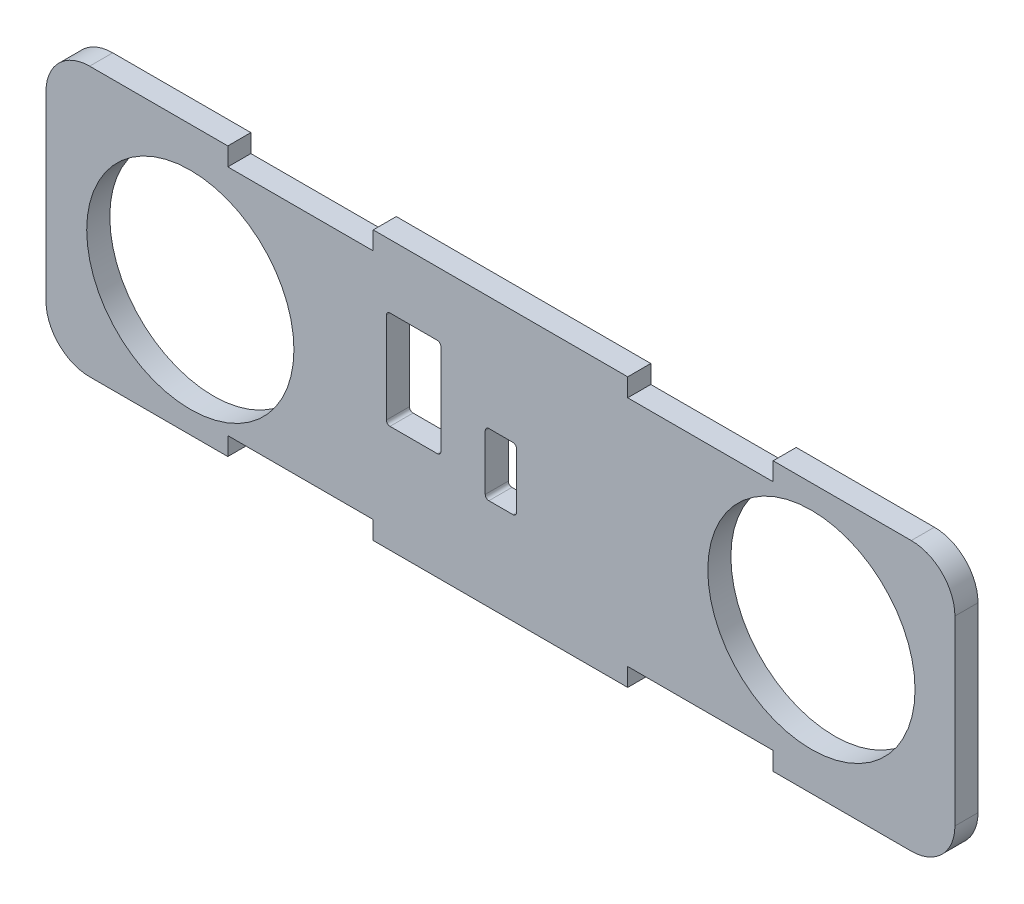
from build123d import *

# Parameters (mm, degrees)
SKETCH1_W           = 125
SKETCH1_H           = 37
BOSS_EXTRUDE1_DEPTH = 3.175
FILLET1_R           = 6
CUT_EXTRUDE1_REACH  = 5.175
SKETCH3_R           = 14.25
SKETCH3_W           = 4.3
SKETCH3_H           = 8.6
SKETCH3_W_2         = 7.5
SKETCH3_H_2         = 13.5
SKETCH6_W           = 20
SKETCH6_H           = 2.5
CUT_EXTRUDE2_DEPTH  = 4.175
FILLET2_R           = 0.5


with BuildPart() as part:
    # Sketch1 → Boss-Extrude1 (new body)
    with BuildSketch(Plane.XY):
        Rectangle(SKETCH1_W, SKETCH1_H)
    extrude(amount=BOSS_EXTRUDE1_DEPTH)

    # Fillet1
    fillet1_edges = [part.edges().sort_by_distance(p)[0] for p in [
        (62.5, -18.5, 1.5875),
        (-62.5, -18.5, 1.5875),
        (-62.5, 18.5, 1.5875),
        (62.5, 18.5, 1.5875),
    ]]
    fillet(fillet1_edges, radius=FILLET1_R)

    # Sketch3 → Cut-Extrude1 (cut, up to next)
    with BuildSketch(Plane.XY.offset(3.175), mode=Mode.PRIVATE) as cut_extrude1_sk1:
        with Locations((42.7653, 1)):
            Circle(SKETCH3_R)
    cut_extrude1_tool1 = extrude(cut_extrude1_sk1.sketch, amount=-CUT_EXTRUDE1_REACH, mode=Mode.PRIVATE) & part.part
    add(cut_extrude1_tool1.solids().sort_by_distance((42.7653, 1, 3.175))[0], mode=Mode.SUBTRACT)
    # Sketch3 → Cut-Extrude1 (cut, up to next)
    with BuildSketch(Plane.XY.offset(3.175), mode=Mode.PRIVATE) as cut_extrude1_sk2:
        with Locations((-42.6527, -1.2074)):
            Circle(SKETCH3_R)
    cut_extrude1_tool2 = extrude(cut_extrude1_sk2.sketch, amount=-CUT_EXTRUDE1_REACH, mode=Mode.PRIVATE) & part.part
    add(cut_extrude1_tool2.solids().sort_by_distance((-42.6527, -1.2074, 3.175))[0], mode=Mode.SUBTRACT)
    # Sketch3 → Cut-Extrude1 (cut, up to next)
    with BuildSketch(Plane.XY.offset(3.175), mode=Mode.PRIVATE) as cut_extrude1_sk3:
        with Locations((0.0563, -1.5037)):
            Rectangle(SKETCH3_W, SKETCH3_H)
    cut_extrude1_tool3 = extrude(cut_extrude1_sk3.sketch, amount=-CUT_EXTRUDE1_REACH, mode=Mode.PRIVATE) & part.part
    add(cut_extrude1_tool3.solids().sort_by_distance((0.0563, -1.5037, 3.175))[0], mode=Mode.SUBTRACT)
    # Sketch3 → Cut-Extrude1 (cut, up to next)
    with BuildSketch(Plane.XY.offset(3.175), mode=Mode.PRIVATE) as cut_extrude1_sk4:
        with Locations((-11.9437, 3.003839217)):
            Rectangle(SKETCH3_W_2, SKETCH3_H_2)
    cut_extrude1_tool4 = extrude(cut_extrude1_sk4.sketch, amount=-CUT_EXTRUDE1_REACH, mode=Mode.PRIVATE) & part.part
    add(cut_extrude1_tool4.solids().sort_by_distance((-11.9437, 3.003839, 3.175))[0], mode=Mode.SUBTRACT)

    # Sketch6 → Cut-Extrude2 (cut, through all)
    with BuildSketch(Plane.XY.offset(3.175)):
        with Locations((27.5, -17.25)):
            Rectangle(SKETCH6_W, SKETCH6_H)
        with Locations((-27.5, -17.25)):
            Rectangle(SKETCH6_W, SKETCH6_H)
        with Locations((-27.5, 17.25)):
            Rectangle(SKETCH6_W, SKETCH6_H)
        with Locations((27.5, 17.25)):
            Rectangle(SKETCH6_W, SKETCH6_H)
    extrude(amount=-CUT_EXTRUDE2_DEPTH, mode=Mode.SUBTRACT)

    # Fillet2
    fillet2_edges = [part.edges().sort_by_distance(p)[0] for p in [
        (-15.6937, -3.746160783, 1.5875),
        (-15.6937, 9.753839217, 1.5875),
        (-8.1937, 9.753839217, 1.5875),
        (-8.1937, -3.746160783, 1.5875),
        (2.2063, 2.7963, 1.5875),
        (2.2063, -5.8037, 1.5875),
        (-2.0937, -5.8037, 1.5875),
        (-2.0937, 2.7963, 1.5875),
    ]]
    fillet(fillet2_edges, radius=FILLET2_R)


solid = part.part
